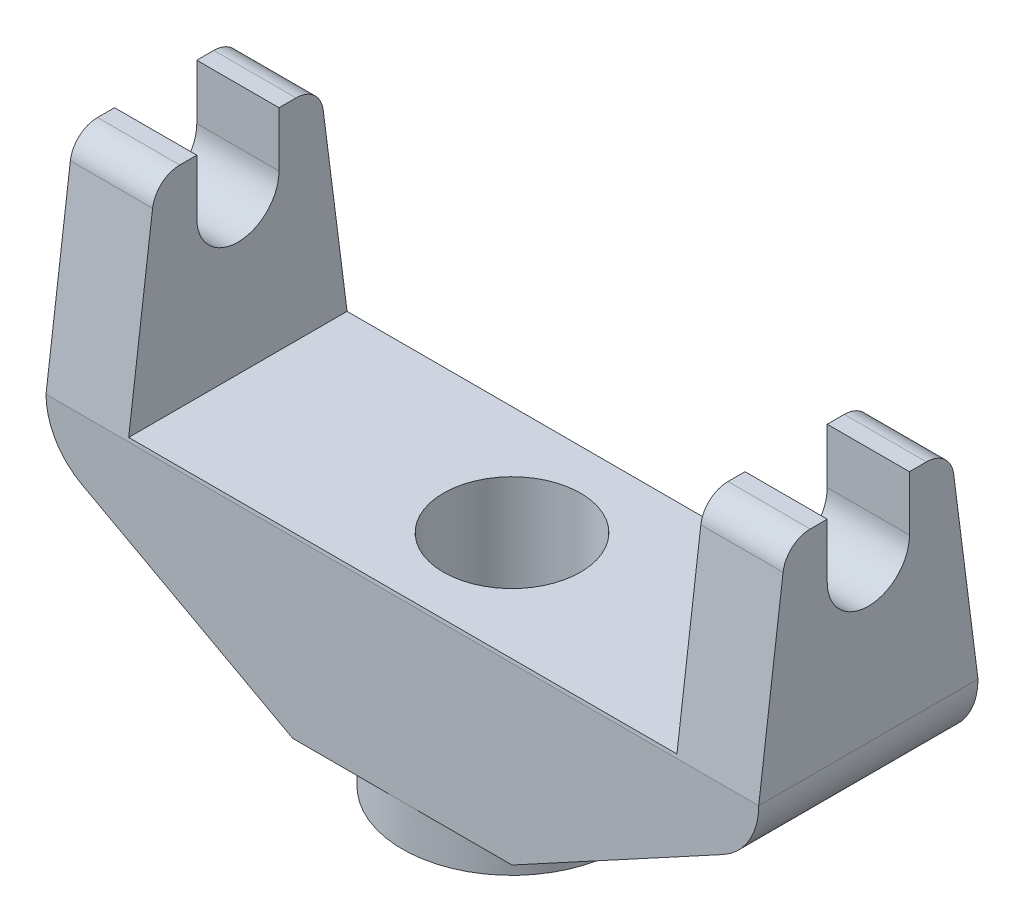
from build123d import *

# Parameters (mm, degrees)
BOSS_EXTRUDE1_DEPTH = 50.8
SKETCH2_R           = 50.8
BOSS_EXTRUDE2_DEPTH = 19.05
SKETCH3_R           = 31.75
CUT_EXTRUDE1_DEPTH  = 102.6
CUT_EXTRUDE2_DEPTH  = 331.2
FILLET1_R           = 12.7


with BuildPart() as part:
    # Sketch1 → Boss-Extrude1 (new body, symmetric)
    with BuildSketch(Plane.XY):
        with BuildLine():
            Line((-50.8, 0), (50.8, 0))
            Line((50.8, 0), (148.497855998, 53.036837313))
            ThreePointArc((148.497855998, 53.036837313), (160.635590775, 64.705829567), (165.1, 80.940330977))
            Line((165.1, 80.940330977), (165.1, 180.036837313))
            Line((165.1, 180.036837313), (127, 180.036837313))
            Line((127, 180.036837313), (127, 82.55))
            Line((127, 82.55), (-127, 82.55))
            Line((-127, 82.55), (-127, 180.036837313))
            Line((-127, 180.036837313), (-165.1, 180.036837313))
            Line((-165.1, 180.036837313), (-165.1, 80.940330977))
            ThreePointArc((-165.1, 80.940330977), (-160.635590775, 64.705829567), (-148.497855998, 53.036837313))
            Line((-148.497855998, 53.036837313), (-50.8, 0))
        make_face()
    extrude(amount=BOSS_EXTRUDE1_DEPTH, both=True)

    # Sketch2 → Boss-Extrude2 (add)
    with BuildSketch(Plane.XZ):
        Circle(SKETCH2_R)
    extrude(amount=BOSS_EXTRUDE2_DEPTH)

    # Sketch3 → Cut-Extrude1 (cut, through all)
    with BuildSketch(Plane(origin=(0, 82.55, 0), x_dir=(1, 0, 0), z_dir=(0, 1, 0))):
        Circle(SKETCH3_R)
    extrude(amount=-CUT_EXTRUDE1_DEPTH, mode=Mode.SUBTRACT)

    # Sketch4 → Cut-Extrude2 (cut, through all)
    with BuildSketch(Plane(origin=(165.1, 0, 0), x_dir=(0, 0, -1), z_dir=(1, 0, 0))):
        Polygon((-50.8, 180.036837313), (-50.8, 80.940330977), (-38.1, 180.036837313), align=None)
        with BuildLine():
            Line((19.05, 180.036837313), (-19.05, 180.036837313))
            Line((-19.05, 180.036837313), (-19.05, 154.636837313))
            ThreePointArc((-19.05, 154.636837313), (0, 135.586837313), (19.05, 154.636837313))
            Line((19.05, 154.636837313), (19.05, 180.036837313))
        make_face()
        Polygon((38.1, 180.036837313), (50.8, 80.940330977), (50.8, 180.036837313), align=None)
    extrude(amount=-CUT_EXTRUDE2_DEPTH, mode=Mode.SUBTRACT)

    # Fillet1
    fillet1_edges = [part.edges().sort_by_distance(p)[0] for p in [
        (146.05, 180.036837313, -38.1),
        (-146.05, 180.036837313, -38.1),
        (146.05, 180.036837313, 38.1),
        (-146.05, 180.036837313, 38.1),
    ]]
    fillet(fillet1_edges, radius=FILLET1_R)


solid = part.part
